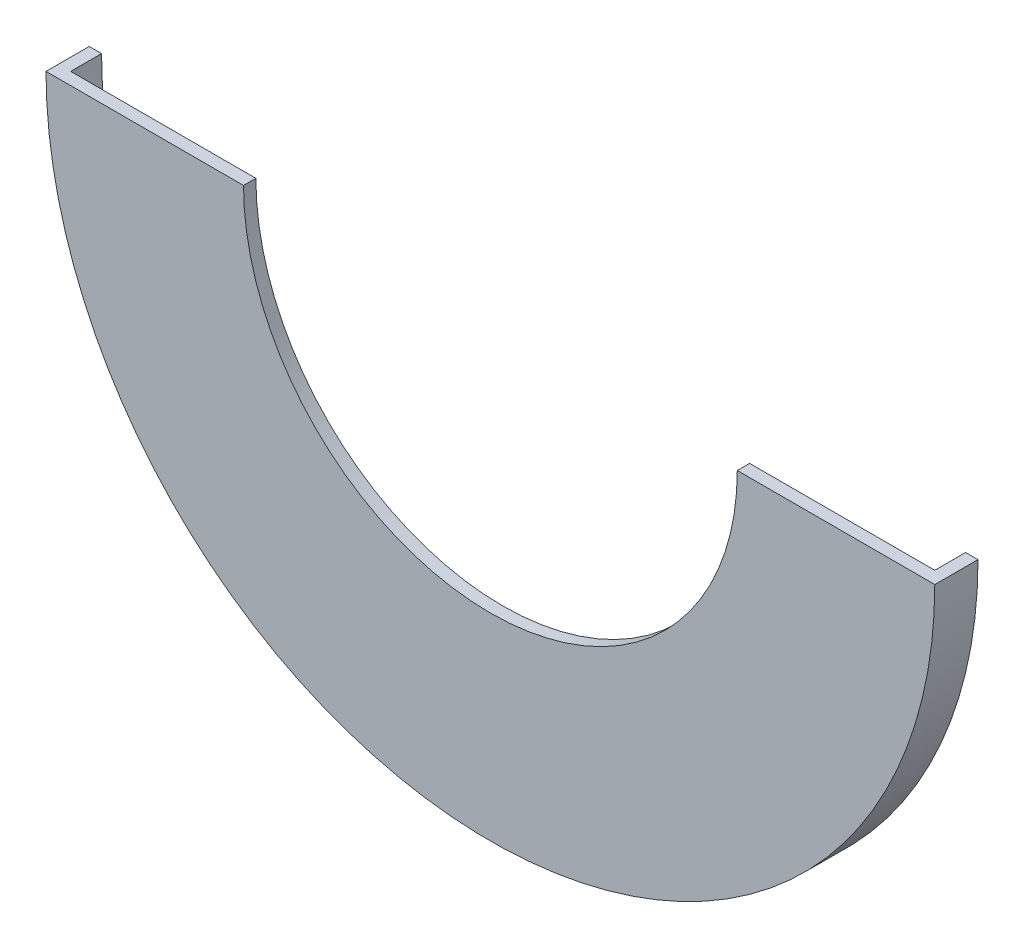
from build123d import *

# Parameters (mm, degrees)
BOSS_EXTRUDE1_DEPTH = 5
BOSS_EXTRUDE2_DEPTH = 2


with BuildPart() as part:
    # Sketch1 → Boss-Extrude1 (new body)
    with BuildSketch(Plane.XY):
        with BuildLine():
            Line((72, 0), (70, 0))
            ThreePointArc((70, 0), (0, -70), (-70, 0))
            Line((-70, 0), (-72, 0))
            ThreePointArc((-72, 0), (0, -72), (72, 0))
        make_face()
    extrude(amount=BOSS_EXTRUDE1_DEPTH)

    # Sketch2 → Boss-Extrude2 (add)
    with BuildSketch(Plane.XY.offset(5)):
        with BuildLine():
            Line((72, 0), (70, 0))
            ThreePointArc((70, 0), (0, -70), (-70, 0))
            Line((-70, 0), (-72, 0))
            ThreePointArc((-72, 0), (0, -72), (72, 0))
        make_face()
        with BuildLine():
            Line((-40, 0), (-70, 0))
            ThreePointArc((-70, 0), (0, -70), (70, 0))
            Line((70, 0), (40, 0))
            ThreePointArc((40, 0), (0, -40), (-40, 0))
        make_face()
    extrude(amount=BOSS_EXTRUDE2_DEPTH)


solid = part.part
